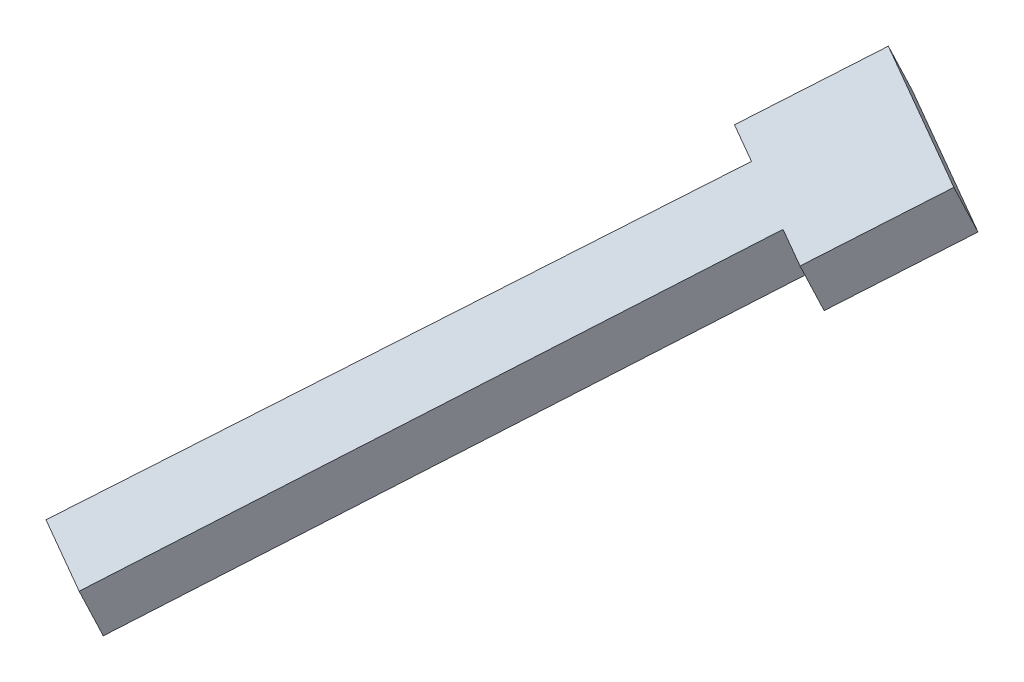
from build123d import *

# Parameters (mm, degrees)
BOSS_EXTRUDE1_DEPTH = 15.75
CUT_EXTRUDE1_DEPTH  = 29.12540638


with BuildPart() as part:
    # Sketch1 → Boss-Extrude1 (new body)
    with BuildSketch(Plane(origin=(-15.864839006, 0, -9.159569071), x_dir=(0.5, 0, -0.866025404), z_dir=(0.866025404, 0, 0.5))):
        Polygon((-250.897888289, -141.485825414), (-306.1863183, -164.792251717), (-304.632556546, -168.478147051), (-249.344126536, -145.171720748), align=None)
    extrude(amount=-BOSS_EXTRUDE1_DEPTH)

    # Sketch2 → Cut-Extrude1 (cut, through all)
    with BuildSketch(Plane(origin=(6.393069309, -30.331785785, -11.073120859), x_dir=(0.980957953, 0.182442937, 0.066603816), z_dir=(-0.194220219, 0.921473834, 0.336399287))):
        Polygon((-192.659600657, -289.596321832), (-189.22286398, -291.424710992), (-165.922780405, -248.036843291), (-175.386750656, -243.001886517), (-198.517574459, -286.479802644), align=None)
        Polygon((-149.766129503, -256.632394287), (-172.896953306, -300.110310414), (-178.754927107, -296.993791227), (-182.191663785, -295.165402067), (-159.230099754, -251.597437512), align=None)
    extrude(amount=-CUT_EXTRUDE1_DEPTH, mode=Mode.SUBTRACT)


solid = part.part
